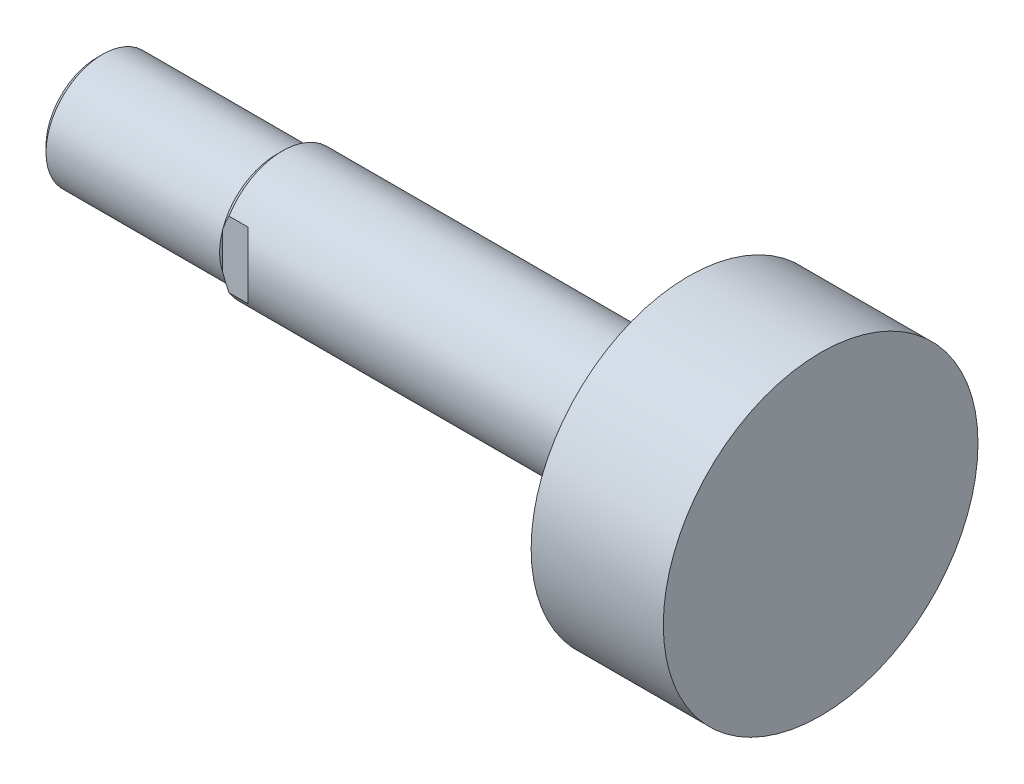
from build123d import *

# Parameters (mm, degrees)
CUT_EXTRUDE_1_DEPTH      = 17
CUT_EXTRUDE_1_DEPTH_BACK = 17


with BuildPart() as part:
    # 草图1 → 旋转1 (revolve)
    with BuildSketch(Plane.XY):
        Polygon((0, 0), (0, 10), (60.5, 10), (60.5, 25), (81.5, 25), (81.5, 0), align=None)
    revolve(axis=Axis((81.5, 0, 0), (-1, 0, 0)))

    # 草图2 → 旋转2 (revolve)
    with BuildSketch(Plane.XY):
        Polygon((-33.5, 0), (-33.5, 8.08), (-32.58, 9), (-5, 9), (-4, 10), (0, 10), (0, 0), align=None)
    revolve(axis=Axis((0, 0, 0), (-1, 0, 0)))

    # 草图3 → 切除-拉伸1 (cut, two sides: drawn at the far end of the back side and taken through both)
    with BuildSketch(Plane(origin=(0, 0, 0), x_dir=(1, 0, 0), z_dir=(0, 1, 0)).offset(-CUT_EXTRUDE_1_DEPTH_BACK)):
        Polygon((-43.5, -28.5), (19, -28.5), (-1, -8.5), (-5, -8.5), (-5, -18.5), (-33.5, -18.5), (-33.5, 18.5), (-5, 18.5), (-5, 8.5), (-1, 8.5), (19, 28.5), (-43.5, 28.5), align=None)
    extrude(amount=CUT_EXTRUDE_1_DEPTH + CUT_EXTRUDE_1_DEPTH_BACK, mode=Mode.SUBTRACT)


solid = part.part
